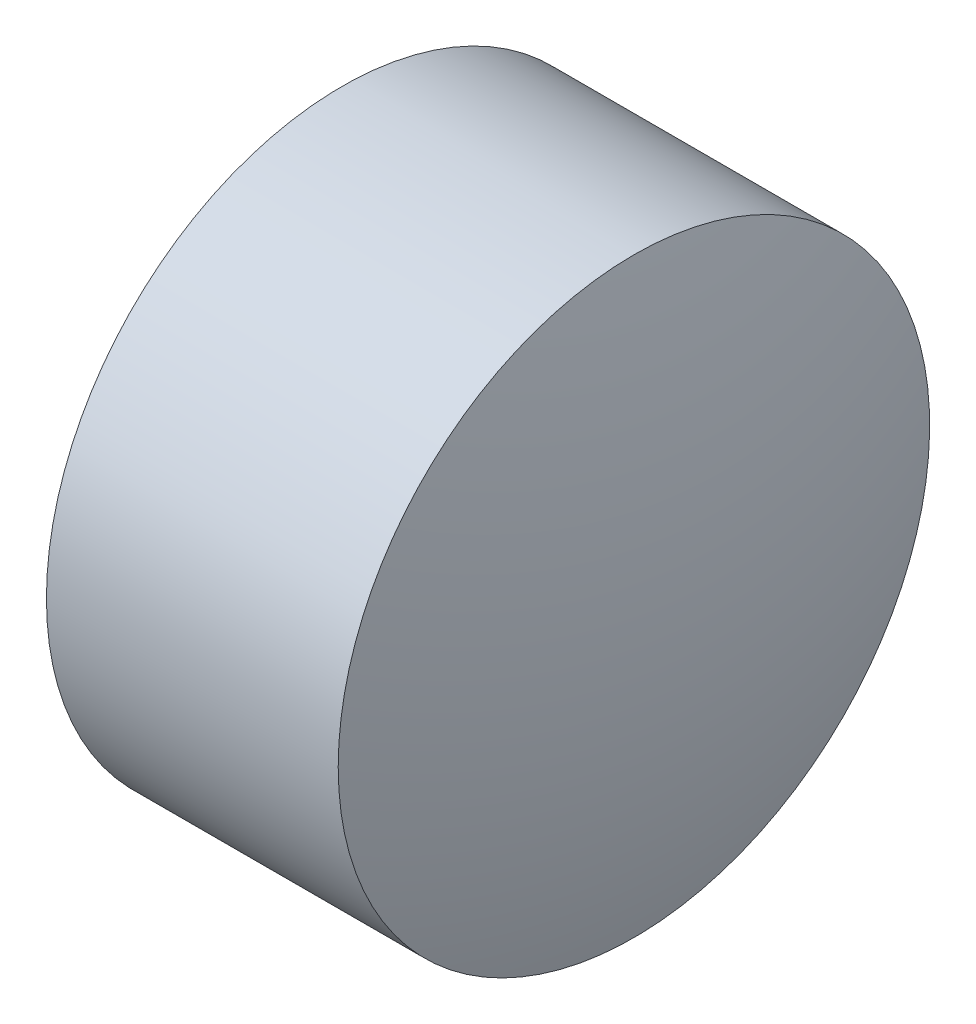
from build123d import *


with BuildPart() as part:
    # 草图1 → 旋转1 (revolve)
    with BuildSketch(Plane.XY):
        with BuildLine():
            Line((588.141965252, 193.842178515), (586.661965252, 193.842178515))
            Line((586.661965252, 193.842178515), (586.661965252, 192.342178515))
            Line((586.661965252, 192.342178515), (588.361965252, 192.342178515))
            ThreePointArc((588.361965252, 192.342178515), (588.306672613, 193.100202261), (588.141965252, 193.842178515))
        make_face()
    revolve(axis=Axis((586.522561634, 192.342178515, 0), (1, 0, 0)))


solid = part.part
